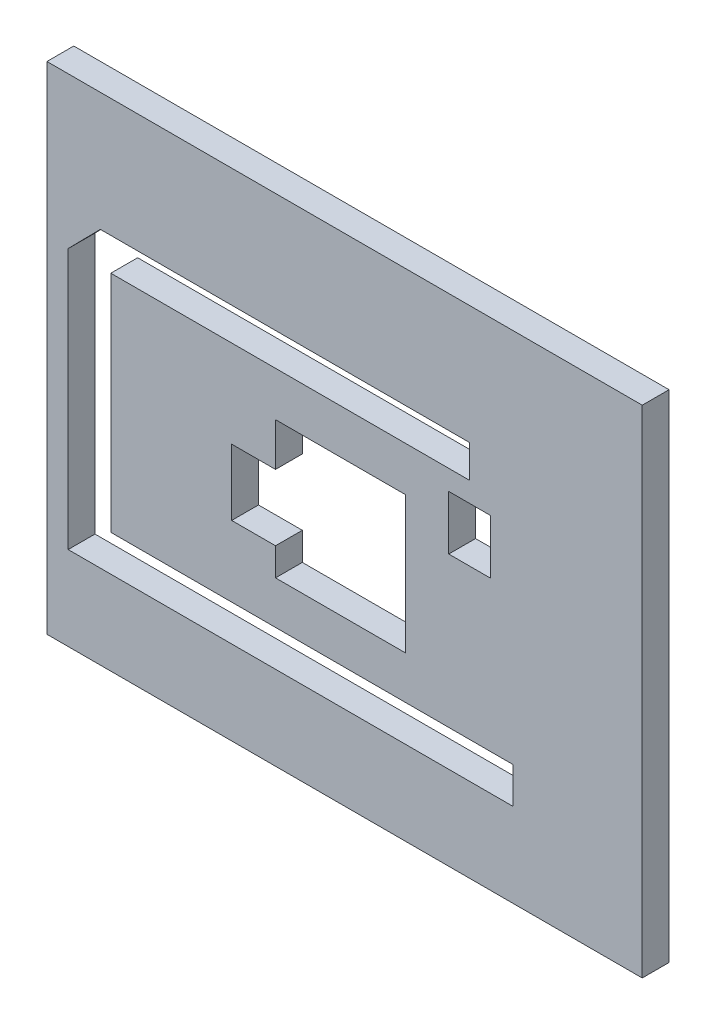
from build123d import *

# Parameters (mm, degrees)
CROQUIS1_W              = 111
CROQUIS1_H              = 86.5
CROQUIS1_W_2            = 7.783251258
CROQUIS1_H_2            = 10.118226634
SALIENTE_EXTRUIR1_DEPTH = 5
CROQUIS3_W              = 111
CROQUIS3_H              = 5
SALIENTE_EXTRUIR2_DEPTH = 6


with BuildPart() as part:
    # Croquis1 → Saliente-Extruir1 (new body)
    with BuildSketch(Plane.XY):
        with Locations((50.205582562, 38.585714286)):
            Rectangle(CROQUIS1_W, CROQUIS1_H)
        Polygon((-1.339906851, 59.600947476), (4.653483533, 65.703308594), (73.52298758, 65.703308594), (73.52298758, 59.600947476), (6.614956749, 59.600947476), (6.614956749, 17.756185524), (81.586821915, 17.756185524), (81.586821915, 11), (6.614956749, 11), (-1.339906851, 11), align=None, mode=Mode.SUBTRACT)
        Polygon((29.151946634, 43.268500853), (37.324360454, 43.268500853), (37.324360454, 51.311193819), (61.582160207, 51.311193819), (61.582160207, 25.756185524), (37.324360454, 25.756185524), (37.324360454, 30.945019695), (29.151946634, 30.945019695), align=None, mode=Mode.SUBTRACT)
        with Locations((73.516478802, 50.815298841)):
            Rectangle(CROQUIS1_W_2, CROQUIS1_H_2, mode=Mode.SUBTRACT)
    extrude(amount=SALIENTE_EXTRUIR1_DEPTH)

    # Croquis3 → Saliente-Extruir2 (add)
    with BuildSketch(Plane(origin=(0, 81.835714286, 0), x_dir=(1, 0, 0), z_dir=(0, 1, 0))):
        with Locations((50.205582562, -2.5)):
            Rectangle(CROQUIS3_W, CROQUIS3_H)
    extrude(amount=SALIENTE_EXTRUIR2_DEPTH)


solid = part.part
